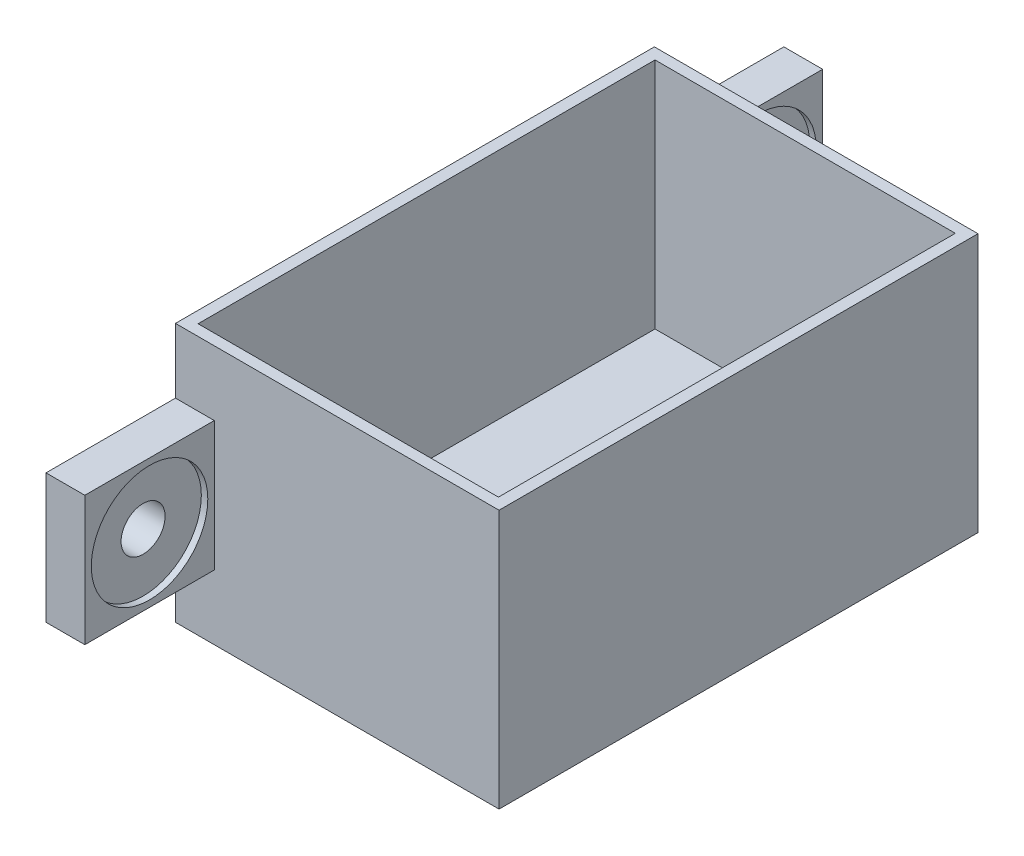
from build123d import *

# Parameters (mm, degrees)
SKETCH1_W                                            = 25
SKETCH1_H                                            = 37
BOSS_EXTRUDE2_DEPTH                                  = 20
SKETCH4_W                                            = 23.2
SKETCH4_H                                            = 35.3
CUT_EXTRUDE1_DEPTH                                   = 18
SKETCH30_W                                           = 10
SKETCH30_H                                           = 10
BOSS_EXTRUDE5_DEPTH                                  = 3
CBORE_FOR_M3_HEXAGON_HEAD_BOLTS_FULL_THR_D           = 3.4
CBORE_FOR_M3_HEXAGON_HEAD_BOLTS_FULL_THR_CBORE_D     = 9
CBORE_FOR_M3_HEXAGON_HEAD_BOLTS_FULL_THR_CBORE_DEPTH = 0.5


with BuildPart() as part:
    # Sketch1 → Boss-Extrude2 (new body)
    with BuildSketch(Plane(origin=(0, 0, 0), x_dir=(1, 0, 0), z_dir=(0, 1, 0))):
        with Locations((-76.226170177, 10.94482429)):
            Rectangle(SKETCH1_W, SKETCH1_H)
    extrude(amount=BOSS_EXTRUDE2_DEPTH)

    # Sketch4 → Cut-Extrude1 (cut)
    with BuildSketch(Plane(origin=(0, 20, 0), x_dir=(1, 0, 0), z_dir=(0, 1, 0))):
        with Locations((-76.226170177, 10.94482429)):
            Rectangle(SKETCH4_W, SKETCH4_H)
    extrude(amount=-CUT_EXTRUDE1_DEPTH, mode=Mode.SUBTRACT)

    # Sketch30 → Boss-Extrude5 (add)
    with BuildSketch(Plane.ZY.offset(88.726170177)):
        with Locations((-34.44482429, 10)):
            Rectangle(SKETCH30_W, SKETCH30_H)
        with Locations((12.55517571, 10)):
            Rectangle(SKETCH30_W, SKETCH30_H)
    extrude(amount=-BOSS_EXTRUDE5_DEPTH)

    # CBORE for M3 Hexagon head bolts-Full thread-grades AB5 (through all)
    with Locations(Plane(origin=(-85.726170177, 10, -34.44482429), x_dir=(0, 0, 1), z_dir=(1, 0, 0))):
        with Locations((0, 0), (47, 0)):
            CounterBoreHole(CBORE_FOR_M3_HEXAGON_HEAD_BOLTS_FULL_THR_D / 2, CBORE_FOR_M3_HEXAGON_HEAD_BOLTS_FULL_THR_CBORE_D / 2, CBORE_FOR_M3_HEXAGON_HEAD_BOLTS_FULL_THR_CBORE_DEPTH)


solid = part.part
